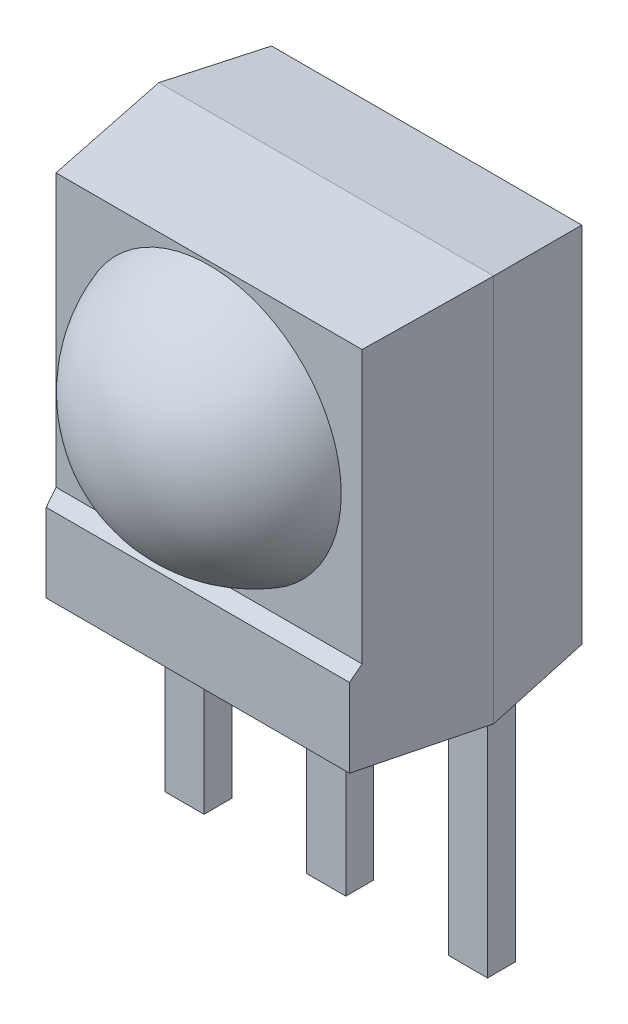
from build123d import *

# Parameters (mm, degrees)
BOSS_EXTRU_1_DEPTH             = 3
ENL_V_MAT_EXTRU_4_DEPTH        = 8.911542201
BOSS_EXTRU_2_REACH             = 10.47
ESQUISSE4_W                    = 0.7
ESQUISSE4_H                    = 0.5
BOSS_EXTRU_2_DIRECTION_2_DEPTH = 4


with BuildPart() as part:
    # Esquisse1 → Boss.-Extru.1 (new, symmetric)
    with BuildSketch(Plane(origin=(0, 0, 0), x_dir=(0, 0, -1), z_dir=(1, 0, 0))):
        Polygon((0, 6.95), (1.8, 6.72898779), (1.8, 0.22101221), (0, 0), (-2.1, 0.22101221), (-2.3, 0.242060991), (-2.3, 1.65), (-2.1, 1.85), (-2.1, 6.72898779), align=None)
    extrude(amount=BOSS_EXTRU_1_DEPTH, both=True)

    # Esquisse2 → Enlèv. mat.-Extru.4 (cut, symmetric)
    with BuildSketch(Plane(origin=(0, 0, 0), x_dir=(1, 0, 0), z_dir=(0, 1, 0))):
        Polygon((0.22814949, -26.29116777), (-2.71759551, -2.3), (-3, 0), (-2.77898779, 1.8), (0.16675721, 25.79116777), (-48.17588371, 25.734183671), (-48.11449143, -26.348151869), align=None)
    enl_v_mat_extru_4 = extrude(amount=ENL_V_MAT_EXTRU_4_DEPTH, both=True, mode=Mode.SUBTRACT)

    # Esquisse3 → Révolution1 (revolve)
    with BuildSketch(Plane(origin=(0, 4.3, 0), x_dir=(-1, 0, 0), z_dir=(0, 1, 0))):
        with BuildLine():
            Line((0, 2.1), (2.368543856, 2.1))
            ThreePointArc((2.368543856, 2.1), (1.457737974, 3.331009601), (0, 3.8))
            Line((0, 3.8), (0, 2.1))
        make_face()
    revolve(axis=Axis((0, 4.3, 2.1), (0, 0, 1)))

    # Symétrie1: Enlèv. mat.-Extru.4 across plane
    add(enl_v_mat_extru_4.mirror(Plane(origin=(0, 0, 0), x_dir=(0, 0, 1), z_dir=(1, 0, 0))), mode=Mode.SUBTRACT)

    # Esquisse4 → Boss.-Extru.2 (add, up to next)
    with BuildSketch(Plane(origin=(0, 0, 0), x_dir=(1, 0, 0), z_dir=(0, 1, 0)), mode=Mode.PRIVATE) as boss_extru_2_sk1:
        with Locations((0, 0.25)):
            Rectangle(ESQUISSE4_W, ESQUISSE4_H)
    boss_extru_2_tool1 = extrude(boss_extru_2_sk1.sketch, amount=BOSS_EXTRU_2_REACH, mode=Mode.PRIVATE) - part.part
    # Esquisse4 → Boss.-Extru.2 (add, up to next)
    with BuildSketch(Plane(origin=(0, 0, 0), x_dir=(1, 0, 0), z_dir=(0, 1, 0)), mode=Mode.PRIVATE) as boss_extru_2_sk2:
        with Locations((2.54, 0.25)):
            Rectangle(ESQUISSE4_W, ESQUISSE4_H)
    boss_extru_2_tool2 = extrude(boss_extru_2_sk2.sketch, amount=BOSS_EXTRU_2_REACH, mode=Mode.PRIVATE) - part.part
    # Esquisse4 → Boss.-Extru.2 (add, up to next)
    with BuildSketch(Plane(origin=(0, 0, 0), x_dir=(1, 0, 0), z_dir=(0, 1, 0)), mode=Mode.PRIVATE) as boss_extru_2_sk3:
        with Locations((-2.54, 0.25)):
            Rectangle(ESQUISSE4_W, ESQUISSE4_H)
    boss_extru_2_tool3 = extrude(boss_extru_2_sk3.sketch, amount=BOSS_EXTRU_2_REACH, mode=Mode.PRIVATE) - part.part
    add(boss_extru_2_tool1.solids().sort_by_distance((0, 0, -0.25))[0])
    add(boss_extru_2_tool2.solids().sort_by_distance((2.54, 0, -0.25))[0])
    add(boss_extru_2_tool3.solids().sort_by_distance((-2.54, 0, -0.25))[0])

    # Esquisse4 → Boss.-Extru.2 direction 2 (add)
    with BuildSketch(Plane(origin=(0, 0, 0), x_dir=(1, 0, 0), z_dir=(0, 1, 0))):
        with Locations((0, 0.25)):
            Rectangle(ESQUISSE4_W, ESQUISSE4_H)
        with Locations((2.54, 0.25)):
            Rectangle(ESQUISSE4_W, ESQUISSE4_H)
        with Locations((-2.54, 0.25)):
            Rectangle(ESQUISSE4_W, ESQUISSE4_H)
    extrude(amount=-BOSS_EXTRU_2_DIRECTION_2_DEPTH)


solid = part.part
